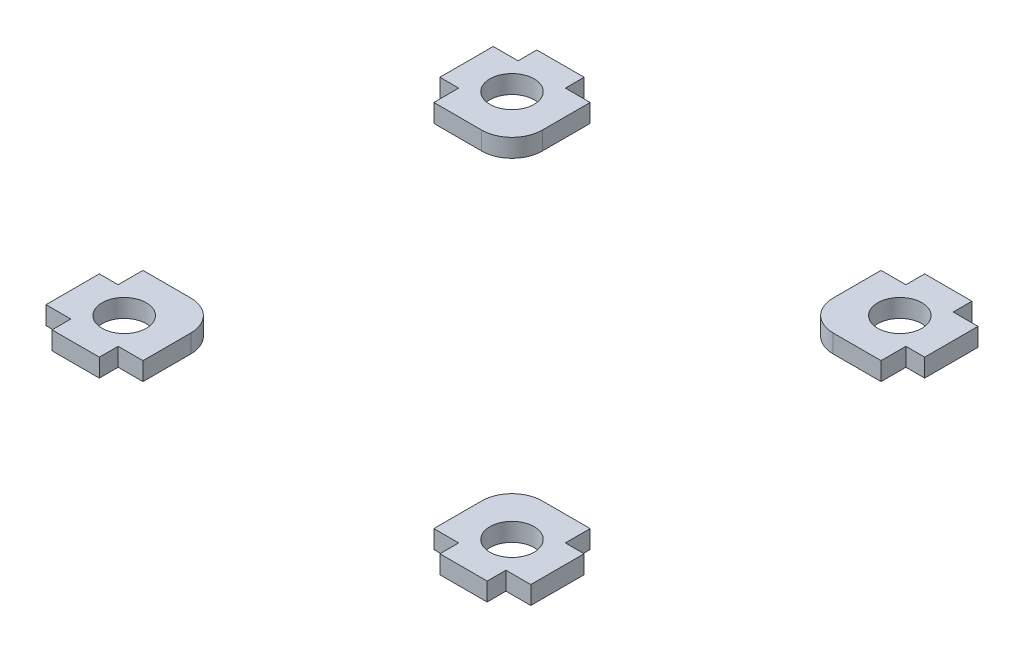
from build123d import *

# Parameters (mm, degrees)
SKETCH1_R             = 3.65
BOSS_EXTRUDE1_DEPTH   = 3
BOSS_EXTRUDE1_2_DEPTH = 3
BOSS_EXTRUDE1_3_DEPTH = 3
BOSS_EXTRUDE1_4_DEPTH = 3
SKETCH3_W             = 4.2
SKETCH3_H             = 3.2
SKETCH3_W_2           = 3.2
SKETCH3_H_2           = 4.2
CUT_EXTRUDE1_DEPTH    = 4


with BuildPart() as part:
    # Sketch1 → Boss-Extrude1 (new body)
    with BuildSketch(Plane(origin=(0, 0, 0), x_dir=(1, 0, 0), z_dir=(0, 1, 0))):
        with BuildLine():
            Line((0, 0), (16, 0))
            Line((16, 0), (16, 11))
            ThreePointArc((16, 11), (14.535533906, 14.535533906), (11, 16))
            Line((11, 16), (0, 16))
            Line((0, 16), (0, 0))
        make_face()
        with Locations((8, 8)):
            Circle(SKETCH1_R, mode=Mode.SUBTRACT)
    extrude(amount=-BOSS_EXTRUDE1_DEPTH)


with BuildPart() as body_2:
    # Sketch1 → Boss-Extrude1 2 (new body)
    with BuildSketch(Plane(origin=(0, 0, 0), x_dir=(1, 0, 0), z_dir=(0, 1, 0))):
        with BuildLine():
            Line((16, 80), (16, 69))
            ThreePointArc((16, 69), (14.535533906, 65.464466094), (11, 64))
            Line((11, 64), (0, 64))
            Line((0, 64), (0, 80))
            Line((0, 80), (16, 80))
        make_face()
        with Locations((8, 72)):
            Circle(SKETCH1_R, mode=Mode.SUBTRACT)
    extrude(amount=-BOSS_EXTRUDE1_2_DEPTH)


with BuildPart() as body_3:
    # Sketch1 → Boss-Extrude1 3 (new body)
    with BuildSketch(Plane(origin=(0, 0, 0), x_dir=(1, 0, 0), z_dir=(0, 1, 0))):
        with BuildLine():
            Line((80, 80), (64, 80))
            Line((64, 80), (64, 69))
            ThreePointArc((64, 69), (65.464466094, 65.464466094), (69, 64))
            Line((69, 64), (80, 64))
            Line((80, 64), (80, 80))
        make_face()
        with Locations((72, 72)):
            Circle(SKETCH1_R, mode=Mode.SUBTRACT)
    extrude(amount=-BOSS_EXTRUDE1_3_DEPTH)


with BuildPart() as body_4:
    # Sketch1 → Boss-Extrude1 4 (new body)
    with BuildSketch(Plane(origin=(0, 0, 0), x_dir=(1, 0, 0), z_dir=(0, 1, 0))):
        with BuildLine():
            Line((64, 0), (64, 11))
            ThreePointArc((64, 11), (65.464466094, 14.535533906), (69, 16))
            Line((69, 16), (80, 16))
            Line((80, 16), (80, 0))
            Line((80, 0), (64, 0))
        make_face()
        with Locations((72, 8)):
            Circle(SKETCH1_R, mode=Mode.SUBTRACT)
    extrude(amount=-BOSS_EXTRUDE1_4_DEPTH)


with BuildPart() as cut_extrude1_tool:
    # Sketch3 → Cut-Extrude1 (new body, through all)
    with BuildSketch(Plane(origin=(0, 0, 0), x_dir=(1, 0, 0), z_dir=(0, 1, 0))):
        with Locations((14, 1.5)):
            Rectangle(SKETCH3_W, SKETCH3_H)
        with Locations((1.5, 66)):
            Rectangle(SKETCH3_W_2, SKETCH3_H_2)
        with Locations((78.5, 14)):
            Rectangle(SKETCH3_W_2, SKETCH3_H_2)
        with Locations((78, 1.5)):
            Rectangle(SKETCH3_W, SKETCH3_H)
        with Locations((2, 1.5)):
            Rectangle(SKETCH3_W, SKETCH3_H)
        with Locations((1.5, 14)):
            Rectangle(SKETCH3_W_2, SKETCH3_H_2)
        with Locations((66, 1.5)):
            Rectangle(SKETCH3_W, SKETCH3_H)
        with Locations((78, 78.5)):
            Rectangle(SKETCH3_W, SKETCH3_H)
        with Locations((66, 78.5)):
            Rectangle(SKETCH3_W, SKETCH3_H)
        with Locations((14, 78.5)):
            Rectangle(SKETCH3_W, SKETCH3_H)
        with Locations((2, 78.5)):
            Rectangle(SKETCH3_W, SKETCH3_H)
        with Locations((78.5, 66)):
            Rectangle(SKETCH3_W_2, SKETCH3_H_2)
    extrude(amount=-CUT_EXTRUDE1_DEPTH)


with BuildPart() as part_1:
    add(part.part)

    # Cut-Extrude1: cut by cut_extrude1_tool
    add(cut_extrude1_tool.part, mode=Mode.SUBTRACT)


with BuildPart() as body_2_1:
    add(body_2.part)

    # Cut-Extrude1: cut by cut_extrude1_tool
    add(cut_extrude1_tool.part, mode=Mode.SUBTRACT)


with BuildPart() as body_3_1:
    add(body_3.part)

    # Cut-Extrude1: cut by cut_extrude1_tool
    add(cut_extrude1_tool.part, mode=Mode.SUBTRACT)


with BuildPart() as body_4_1:
    add(body_4.part)

    # Cut-Extrude1: cut by cut_extrude1_tool
    add(cut_extrude1_tool.part, mode=Mode.SUBTRACT)


solid = Compound([part_1.part, body_2_1.part, body_3_1.part, body_4_1.part])
